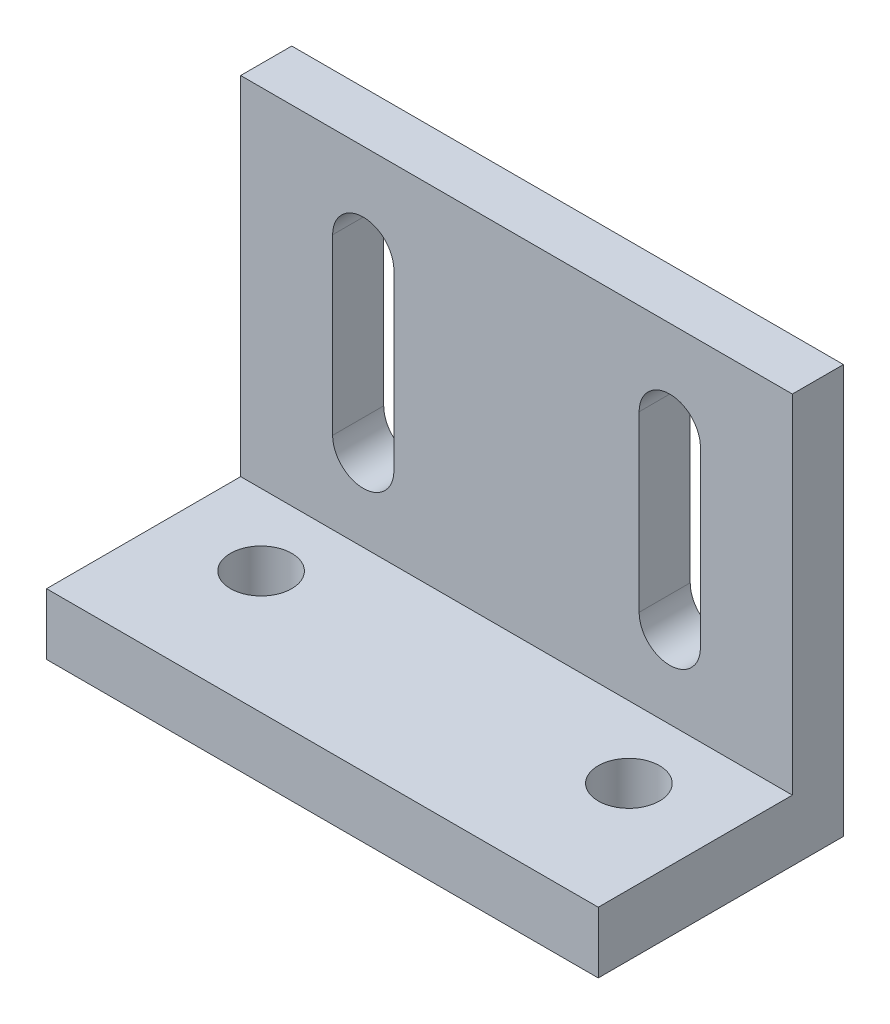
from build123d import *

# Parameters (mm, degrees)
BOSS_EXTRUDE1_DEPTH = 13.5
SKETCH2_R           = 1.5
CUT_EXTRUDE1_DEPTH  = 20
CUT_EXTRUDE2_DEPTH  = 3.5


with BuildPart() as part:
    # Sketch1 → Boss-Extrude1 (new body, symmetric)
    with BuildSketch(Plane(origin=(0, 0, 0), x_dir=(0, 0, -1), z_dir=(1, 0, 0))):
        Polygon((0, 0), (-12, 0), (-12, 3), (-2.5, 3), (-2.5, 20), (0, 20), align=None)
    extrude(amount=BOSS_EXTRUDE1_DEPTH, both=True)

    # Sketch2 → Cut-Extrude1 (cut)
    with BuildSketch(Plane(origin=(0, 3, 0), x_dir=(1, 0, 0), z_dir=(0, 1, 0))):
        with Locations((-9, -6)):
            Circle(SKETCH2_R)
        with Locations((9, -6)):
            Circle(SKETCH2_R)
    extrude(amount=-CUT_EXTRUDE1_DEPTH, mode=Mode.SUBTRACT)

    # Sketch3 → Cut-Extrude2 (cut, through all)
    with BuildSketch(Plane.XY.offset(2.5)):
        with BuildLine():
            Line((-6.000505089, 15.5), (-6.000505089, 7))
            ThreePointArc((-6.000505089, 7), (-7.5, 5.500505089), (-8.999494911, 7))
            Line((-8.999494911, 7), (-8.999494911, 15.5))
            ThreePointArc((-8.999494911, 15.5), (-7.5, 16.999494911), (-6.000505089, 15.5))
        make_face()
        with BuildLine():
            Line((8.999494911, 15.5), (8.999494911, 7))
            ThreePointArc((8.999494911, 7), (7.5, 5.500505089), (6.000505089, 7))
            Line((6.000505089, 7), (6.000505089, 15.5))
            ThreePointArc((6.000505089, 15.5), (7.5, 16.999494911), (8.999494911, 15.5))
        make_face()
    extrude(amount=-CUT_EXTRUDE2_DEPTH, mode=Mode.SUBTRACT)


solid = part.part
